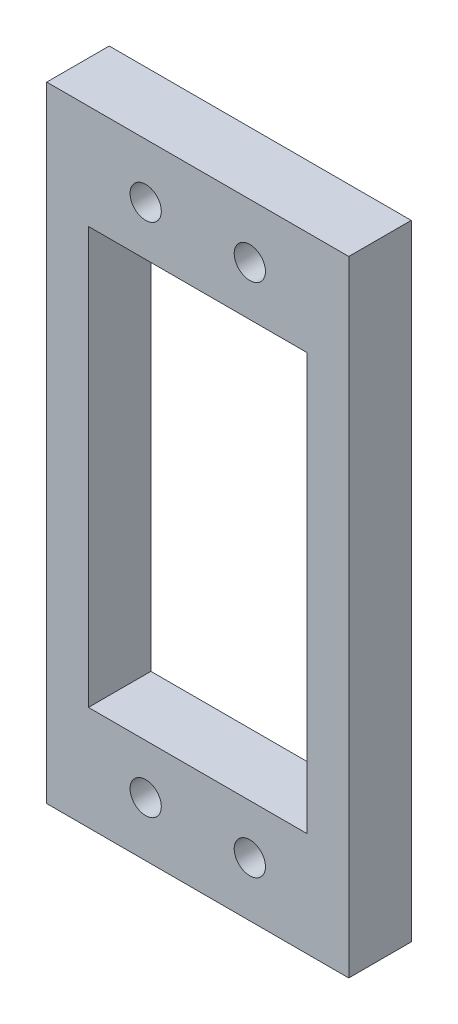
from build123d import *

# Parameters (mm, degrees)
ESBO_O1_W                = 29
ESBO_O1_H                = 60
ESBO_O1_R                = 1.5
ESBO_O1_W_2              = 21
ESBO_O1_H_2              = 40
RESSALTO_EXTRUS_O1_DEPTH = 6


with BuildPart() as part:
    # Esboço1 → Ressalto-extrusão1 (new body)
    with BuildSketch(Plane.XY):
        Rectangle(ESBO_O1_W, ESBO_O1_H)
        with Locations((5, 24.75)):
            Circle(ESBO_O1_R, mode=Mode.SUBTRACT)
        with Locations((-5, 24.75)):
            Circle(ESBO_O1_R, mode=Mode.SUBTRACT)
        with Locations((5, -24.75)):
            Circle(ESBO_O1_R, mode=Mode.SUBTRACT)
        with Locations((-5, -24.75)):
            Circle(ESBO_O1_R, mode=Mode.SUBTRACT)
        Rectangle(ESBO_O1_W_2, ESBO_O1_H_2, mode=Mode.SUBTRACT)
    extrude(amount=RESSALTO_EXTRUS_O1_DEPTH)


solid = part.part
